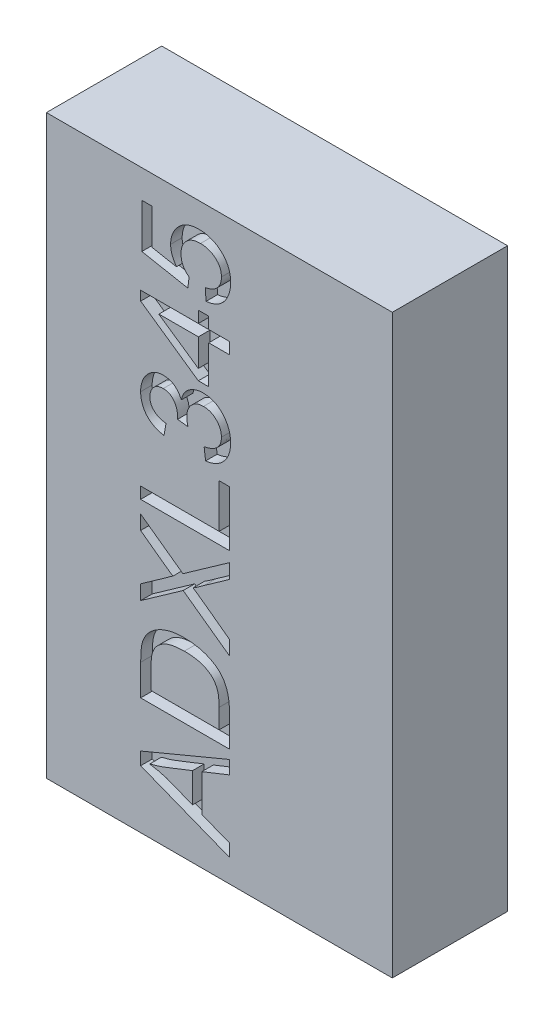
from build123d import *

# Parameters (mm, degrees)
ESQUISSE1_W             = 3
ESQUISSE1_H             = 5
BOSS_EXTRU_1_DEPTH      = 1
ENL_V_MAT_EXTRU_1_DEPTH = 0.1


with BuildPart() as part:
    # Esquisse1 → Boss.-Extru.1 (new body)
    with BuildSketch(Plane.XY):
        with Locations((1.5, 2.5)):
            Rectangle(ESQUISSE1_W, ESQUISSE1_H)
    extrude(amount=BOSS_EXTRU_1_DEPTH)

    # Esquisse2 → Enlèv. mat.-Extru.1 (cut)
    with BuildSketch(Plane(origin=(3.575593403, -1.280169581, 1), x_dir=(0, 1, 0), z_dir=(0, 0, 1))):
        Polygon((2.215385563, 1.987701117), (2.099373441, 1.987701117), (2.003843243, 2.227855591), (1.682699173, 2.227855591), (1.58826343, 1.987701117), (1.479912485, 1.987701117), (1.783232589, 2.758196722), (1.893616091, 2.758196722), align=None)
        with BuildLine():
            add(Edge.make_bspline(
                [(1.971791376, 2.307907082), (1.967832396, 2.31791427), (1.960138748, 2.337361649), (1.948903368, 2.365669848), (1.938184455, 2.392246268), (1.928424558, 2.417266631), (1.919145584, 2.440520895), (1.910707056, 2.462171677), (1.902915421, 2.482142575), (1.895704231, 2.500480169), (1.889117658, 2.517129673), (1.883393014, 2.532182819), (1.878135748, 2.545467514), (1.873830151, 2.557188955), (1.870066319, 2.567191171), (1.866926654, 2.575524808), (1.864399266, 2.582168124), (1.861000969, 2.592157003), (1.856410276, 2.606892042), (1.850228287, 2.627915403), (1.844114017, 2.651854672), (1.839876513, 2.668762643), (1.837642588, 2.677676179)],
                knots=[0, 0, 0, 0, 3.2286e-05, 6.2742e-05, 9.1369e-05, 0.000118254, 0.000143311, 0.00016648, 0.000187966, 0.000207622, 0.000225594, 0.00024168, 0.000255936, 0.000268453, 0.00027914, 0.000287997, 0.00029517, 0.00030046, 0.000319646, 0.000341467, 0.000366192, 0.000393761, 0.000393761, 0.000393761, 0.000393761], degree=3))
            Line((1.837642588, 2.677676179), (1.83545368, 2.677676179))
            add(Edge.make_bspline(
                [(1.83545368, 2.677676179), (1.83336846, 2.664888214), (1.829269492, 2.639750585), (1.821434644, 2.60292826), (1.813052097, 2.567447506), (1.806267044, 2.544489956), (1.802932761, 2.533208253)],
                knots=[0, 0, 0, 0, 3.8865e-05, 7.6397e-05, 0.000112916, 0.000148201, 0.000148201, 0.000148201, 0.000148201], degree=3))
            Line((1.802932761, 2.533208253), (1.714125638, 2.307907082))
            Line((1.714125638, 2.307907082), (1.971791376, 2.307907082))
        make_face(mode=Mode.SUBTRACT)
        with BuildLine():
            Line((2.292935445, 2.758196722), (2.560294919, 2.758196722))
            add(Edge.make_bspline(
                [(2.560294919, 2.758196722), (2.571604659, 2.758090271), (2.593449606, 2.75788466), (2.624961046, 2.756782222), (2.653990214, 2.754303956), (2.680934656, 2.751416211), (2.706472766, 2.746569958), (2.731132519, 2.739222476), (2.755156582, 2.729055549), (2.778577898, 2.716626526), (2.801041672, 2.701598305), (2.822077569, 2.683785157), (2.841655838, 2.663391224), (2.859579481, 2.640466245), (2.875983127, 2.615486677), (2.890545771, 2.588482764), (2.903168928, 2.559645731), (2.914106584, 2.528816993), (2.923012421, 2.495461871), (2.928873872, 2.458901444), (2.93271717, 2.419154718), (2.933132095, 2.391512441), (2.933347377, 2.377170385)],
                knots=[0, 0, 0, 0, 3.3931e-05, 6.5539e-05, 9.4559e-05, 0.000121322, 0.000146803, 0.000172426, 0.000198356, 0.000224936, 0.000251865, 0.000279271, 0.000307468, 0.000336527, 0.000366448, 0.00039702, 0.000428453, 0.000460793, 0.000495077, 0.000531859, 0.000571749, 0.000614763, 0.000614763, 0.000614763, 0.000614763], degree=3))
            add(Edge.make_bspline(
                [(2.933347377, 2.377170385), (2.933137397, 2.363296521), (2.932726033, 2.336116683), (2.928617201, 2.296331795), (2.922533571, 2.258356872), (2.913623297, 2.222258575), (2.902013577, 2.188147171), (2.888079842, 2.155810973), (2.871482366, 2.12545775), (2.855542885, 2.101696656), (2.841471362, 2.083869301), (2.829794824, 2.071552838), (2.817416579, 2.059838403), (2.803978577, 2.049146775), (2.789683323, 2.03915623), (2.774317221, 2.030356629), (2.758158785, 2.022167891), (2.741103805, 2.014805883), (2.723128513, 2.008411154), (2.704190827, 2.00299655), (2.68447037, 1.998054523), (2.663659234, 1.994393829), (2.642012343, 1.991446494), (2.619434065, 1.989221443), (2.595956409, 1.988003718), (2.579996406, 1.987803253), (2.571864861, 1.987701117)],
                knots=[0, 0, 0, 0, 4.1608e-05, 8.1513e-05, 0.000119863, 0.000156912, 0.000192906, 0.000227848, 0.000262413, 0.000296541, 0.00031356, 0.000330484, 0.000347408, 0.000364647, 0.000381952, 0.000399678, 0.000417718, 0.000436277, 0.000455366, 0.00047491, 0.000495349, 0.000516326, 0.00053826, 0.000560881, 0.000584367, 0.000608762, 0.000608762, 0.000608762, 0.000608762], degree=3))
            Line((2.571864861, 1.987701117), (2.292935445, 1.987701117))
            Line((2.292935445, 1.987701117), (2.292935445, 2.758196722))
        make_face()
        with BuildLine():
            Line((2.39299981, 2.077759044), (2.562014775, 2.077759044))
            add(Edge.make_bspline(
                [(2.562014775, 2.077759044), (2.570405931, 2.077877421), (2.586726192, 2.078107657), (2.61052324, 2.079071963), (2.632873027, 2.081260942), (2.654215799, 2.083636886), (2.675069147, 2.088186619), (2.695663361, 2.095690484), (2.716484693, 2.105629542), (2.733564726, 2.116012559), (2.747099247, 2.125858018), (2.756845022, 2.134591049), (2.766191149, 2.144429733), (2.775065522, 2.155362251), (2.783503833, 2.167445308), (2.791528049, 2.180640762), (2.798925558, 2.195006208), (2.806058225, 2.210391847), (2.812480537, 2.227032841), (2.818102897, 2.244990005), (2.822714965, 2.264285756), (2.826669657, 2.284777117), (2.829558194, 2.306606015), (2.831774859, 2.329705357), (2.832983352, 2.354121876), (2.833181512, 2.370810931), (2.833283013, 2.379359293)],
                knots=[0, 0, 0, 0, 2.5177e-05, 4.8967e-05, 7.1418e-05, 9.2537e-05, 0.000113362, 0.000135269, 0.000158138, 0.000182485, 0.000195119, 0.000208298, 0.000221679, 0.000235793, 0.000250498, 0.000265862, 0.000282086, 0.000298947, 0.000316717, 0.000335557, 0.000355352, 0.000376204, 0.000398139, 0.000421382, 0.000445805, 0.00047145, 0.00047145, 0.00047145, 0.00047145], degree=3))
            add(Edge.make_bspline(
                [(2.833283013, 2.379359293), (2.833178673, 2.388848293), (2.832972612, 2.40758823), (2.830869496, 2.435192249), (2.827572834, 2.461849172), (2.823208983, 2.487619074), (2.816768849, 2.512365828), (2.808466474, 2.536173749), (2.797300569, 2.558551379), (2.784496859, 2.579720942), (2.769978886, 2.598900318), (2.754298618, 2.615683159), (2.737483477, 2.629661416), (2.719522804, 2.640474161), (2.701384174, 2.649175759), (2.683428523, 2.656158419), (2.665594203, 2.661017926), (2.647582077, 2.664211526), (2.628491085, 2.665962795), (2.607422229, 2.667176578), (2.583909275, 2.667945294), (2.567383388, 2.668072301), (2.558731413, 2.668138794)],
                knots=[0, 0, 0, 0, 2.8463e-05, 5.6211e-05, 8.2993e-05, 0.000109032, 0.000134554, 0.000159627, 0.00018452, 0.000209431, 0.000233759, 0.000256544, 0.000278204, 0.00029912, 0.00031926, 0.000338511, 0.000356832, 0.00037462, 0.00039332, 0.000414308, 0.00043793, 0.000463886, 0.000463886, 0.000463886, 0.000463886], degree=3))
            Line((2.558731413, 2.668138794), (2.39299981, 2.668138794))
            Line((2.39299981, 2.668138794), (2.39299981, 2.077759044))
        make_face(mode=Mode.SUBTRACT)
        with BuildLine():
            Line((3.693836546, 1.987701117), (3.567505286, 1.987701117))
            Line((3.567505286, 1.987701117), (3.413656326, 2.20549746))
            add(Edge.make_bspline(
                [(3.413656326, 2.20549746), (3.409424593, 2.211274952), (3.40133008, 2.222326215), (3.389902693, 2.23826559), (3.379816461, 2.25275667), (3.370850267, 2.265678925), (3.362954299, 2.276973317), (3.356635761, 2.287057199), (3.351247176, 2.295424188), (3.348234461, 2.300601421), (3.346894633, 2.302903864)],
                knots=[0, 0, 0, 0, 2.1484e-05, 4.1096e-05, 5.8836e-05, 7.445e-05, 8.8284e-05, 0.000100168, 0.000110145, 0.000118135, 0.000118135, 0.000118135, 0.000118135], degree=3))
            Line((3.346894633, 2.302903864), (3.344862076, 2.302903864))
            add(Edge.make_bspline(
                [(3.344862076, 2.302903864), (3.344568653, 2.302112715), (3.343664692, 2.299675384), (3.34066468, 2.295195058), (3.336484823, 2.288121594), (3.330052366, 2.278983783), (3.322137106, 2.267342704), (3.312286891, 2.253512654), (3.300622221, 2.237373259), (3.287449966, 2.21874919), (3.272160434, 2.197939346), (3.255204872, 2.174760416), (3.236569338, 2.149168611), (3.216079645, 2.121343557), (3.193748411, 2.091277213), (3.1697549, 2.058784504), (3.144045422, 2.023956808), (3.126141951, 2.000042162), (3.116902946, 1.987701117)],
                knots=[0, 0, 0, 0, 2.526e-06, 7.782e-06, 1.6068e-05, 2.7213e-05, 4.1265e-05, 5.8313e-05, 7.8143e-05, 0.000101007, 0.000126745, 0.000155609, 0.000187164, 0.000221718, 0.000259274, 0.00029952, 0.000342893, 0.000389141, 0.000389141, 0.000389141, 0.000389141], degree=3))
            Line((3.116902946, 1.987701117), (2.993385996, 1.987701117))
            Line((2.993385996, 1.987701117), (3.283729003, 2.389365729))
            Line((3.283729003, 2.389365729), (3.023405305, 2.758196722))
            Line((3.023405305, 2.758196722), (3.149580215, 2.758196722))
            Line((3.149580215, 2.758196722), (3.309839548, 2.531175695))
            add(Edge.make_bspline(
                [(3.309839548, 2.531175695), (3.313898808, 2.526155768), (3.321616135, 2.516612052), (3.331832326, 2.502556197), (3.34059529, 2.489927671), (3.34542748, 2.48169271), (3.347676386, 2.477860151)],
                knots=[0, 0, 0, 0, 1.9363e-05, 3.6813e-05, 5.2121e-05, 6.5448e-05, 6.5448e-05, 6.5448e-05, 6.5448e-05], degree=3))
            add(Edge.make_bspline(
                [(3.347676386, 2.477860151), (3.348651861, 2.479537046), (3.350972319, 2.483526039), (3.355427719, 2.490169994), (3.360986738, 2.498606823), (3.367950695, 2.508608646), (3.375999439, 2.520376862), (3.385686045, 2.533628475), (3.396289906, 2.548770057), (3.408510787, 2.565368753), (3.421678206, 2.583802213), (3.436239834, 2.603800243), (3.452119378, 2.625454425), (3.469173582, 2.648818792), (3.487784162, 2.673715837), (3.507370045, 2.700431983), (3.52837534, 2.728782142), (3.54284884, 2.748194138), (3.550306724, 2.758196722)],
                knots=[0, 0, 0, 0, 5.819e-06, 1.3841e-05, 2.3989e-05, 3.6132e-05, 5.0401e-05, 6.6759e-05, 8.537e-05, 0.000105855, 0.000128592, 0.00015333, 0.000180067, 0.00020915, 0.000240108, 0.000273318, 0.000308529, 0.00034596, 0.00034596, 0.00034596, 0.00034596], degree=3))
            Line((3.550306724, 2.758196722), (3.673823673, 2.758196722))
            Line((3.673823673, 2.758196722), (3.408809458, 2.391554637))
            Line((3.408809458, 2.391554637), (3.693836546, 1.987701117))
        make_face()
        Polygon((4.264203423, 1.987701117), (3.783894474, 1.987701117), (3.783894474, 2.758196722), (3.883958838, 2.758196722), (3.883958838, 2.077759044), (4.264203423, 2.077759044), align=None)
        with BuildLine():
            add(Edge.make_bspline(
                [(4.708551741, 2.404062683), (4.714413371, 2.402807106), (4.725901575, 2.400346301), (4.74242851, 2.395026365), (4.757740669, 2.388216021), (4.772125473, 2.380493597), (4.785210765, 2.371093415), (4.797213225, 2.360516515), (4.808144698, 2.348606456), (4.817893614, 2.335586929), (4.826336046, 2.321696309), (4.833969354, 2.307549449), (4.84035225, 2.293069643), (4.845551792, 2.278217589), (4.84963253, 2.263122636), (4.85242592, 2.247637233), (4.854190221, 2.231909358), (4.854451983, 2.221293444), (4.854583173, 2.215972948)],
                knots=[0, 0, 0, 0, 1.7977e-05, 3.5233e-05, 5.1965e-05, 6.82e-05, 8.4121e-05, 0.000100183, 0.000116117, 0.000132534, 0.000148891, 0.000164839, 0.00018073, 0.000196306, 0.000212008, 0.000227586, 0.000243471, 0.000259431, 0.000259431, 0.000259431, 0.000259431], degree=3))
            add(Edge.make_bspline(
                [(4.854583173, 2.215972948), (4.854322108, 2.207467322), (4.85380902, 2.190750677), (4.850384804, 2.16625119), (4.844424536, 2.142975441), (4.83601866, 2.120882355), (4.825435809, 2.099810555), (4.812150236, 2.080099666), (4.796707948, 2.061440326), (4.778989878, 2.044326186), (4.759702421, 2.028772941), (4.739300655, 2.015109498), (4.717989196, 2.003442689), (4.69564124, 1.99407496), (4.672429898, 1.98663842), (4.648219796, 1.98156114), (4.623115226, 1.978329245), (4.606047921, 1.977908303), (4.597386486, 1.97769468)],
                knots=[0, 0, 0, 0, 2.5516e-05, 5.0148e-05, 7.4038e-05, 9.7443e-05, 0.000120938, 0.000144614, 0.000168597, 0.000193474, 0.000218381, 0.000242838, 0.000267045, 0.000291148, 0.000315426, 0.000340051, 0.000365262, 0.000391239, 0.000391239, 0.000391239, 0.000391239], degree=3))
            add(Edge.make_bspline(
                [(4.597386486, 1.97769468), (4.589142349, 1.977861368), (4.572969254, 1.97818837), (4.549301769, 1.981154386), (4.526682285, 1.98549626), (4.505299514, 1.992258233), (4.484831144, 2.000432102), (4.465611971, 2.010829625), (4.447464989, 2.022994494), (4.430480977, 2.036794018), (4.415040979, 2.052347993), (4.401068102, 2.069018824), (4.388931531, 2.087079275), (4.378478517, 2.106221389), (4.369814996, 2.126669245), (4.362823916, 2.148220592), (4.357407327, 2.17101582), (4.355323247, 2.186711756), (4.354261351, 2.19470927)],
                knots=[0, 0, 0, 0, 2.4721e-05, 4.8497e-05, 7.1464e-05, 9.3718e-05, 0.000115668, 0.000137493, 0.000159132, 0.000181133, 0.000203023, 0.000224784, 0.000246293, 0.000268192, 0.000290118, 0.000312812, 0.000336098, 0.000360288, 0.000360288, 0.000360288, 0.000360288], degree=3))
            Line((4.354261351, 2.19470927), (4.454325715, 2.207842718))
            add(Edge.make_bspline(
                [(4.454325715, 2.207842718), (4.455498977, 2.201727599), (4.45778023, 2.189837551), (4.462387124, 2.172795697), (4.467499824, 2.156888277), (4.473450868, 2.1421507), (4.480097044, 2.128586686), (4.487533713, 2.116283458), (4.495511741, 2.105087389), (4.504247296, 2.095014189), (4.513878886, 2.086265633), (4.524054603, 2.078489254), (4.535083751, 2.07203959), (4.546876035, 2.066920069), (4.559328437, 2.062818401), (4.57251237, 2.059829306), (4.586449868, 2.058134774), (4.59597487, 2.057877307), (4.600826199, 2.057746172)],
                knots=[0, 0, 0, 0, 1.8674e-05, 3.6309e-05, 5.2922e-05, 6.8774e-05, 8.3948e-05, 9.8186e-05, 0.000111854, 0.00012515, 0.000138097, 0.000150824, 0.000163508, 0.000176319, 0.000189322, 0.000202787, 0.000216809, 0.000231363, 0.000231363, 0.000231363, 0.000231363], degree=3))
            add(Edge.make_bspline(
                [(4.600826199, 2.057746172), (4.606094795, 2.057921998), (4.616462326, 2.05826799), (4.631738685, 2.060239182), (4.646297011, 2.063954477), (4.660374968, 2.068696348), (4.673659296, 2.075299212), (4.686606766, 2.08283107), (4.698597923, 2.092226439), (4.710004873, 2.102625155), (4.720376473, 2.114086301), (4.729522327, 2.126318975), (4.737184358, 2.139250588), (4.74369554, 2.152685585), (4.748562895, 2.166925768), (4.751887554, 2.181772208), (4.754265334, 2.197187315), (4.754433458, 2.20767701), (4.754518808, 2.213002287)],
                knots=[0, 0, 0, 0, 1.5811e-05, 3.1112e-05, 4.6091e-05, 6.0826e-05, 7.5581e-05, 9.0517e-05, 0.000105683, 0.000121176, 0.000136783, 0.000151981, 0.000166916, 0.000181812, 0.000196695, 0.000211941, 0.000227419, 0.000243379, 0.000243379, 0.000243379, 0.000243379], degree=3))
            add(Edge.make_bspline(
                [(4.754518808, 2.213002287), (4.754421958, 2.218118089), (4.754232382, 2.228131805), (4.752050995, 2.242823717), (4.748886394, 2.256899275), (4.744143935, 2.270248175), (4.738094544, 2.282878556), (4.730969625, 2.294975677), (4.722243819, 2.306301226), (4.712288502, 2.316818096), (4.701398277, 2.326502699), (4.689633112, 2.335071732), (4.67690029, 2.342021623), (4.663481873, 2.347924711), (4.649211245, 2.352404613), (4.634153653, 2.35572508), (4.618280369, 2.357587635), (4.607449733, 2.357820425), (4.601920653, 2.357939265)],
                knots=[0, 0, 0, 0, 1.5335e-05, 3.0017e-05, 4.4467e-05, 5.856e-05, 7.2407e-05, 8.6431e-05, 0.000100597, 0.000115197, 0.000129817, 0.000144267, 0.000158754, 0.000173249, 0.000188182, 0.000203546, 0.000219449, 0.000236034, 0.000236034, 0.000236034, 0.000236034], degree=3))
            add(Edge.make_bspline(
                [(4.601920653, 2.357939265), (4.597068619, 2.357805548), (4.586811476, 2.357522873), (4.570682413, 2.35548875), (4.552988375, 2.352375536), (4.540773447, 2.349459687), (4.534377207, 2.347932828)],
                knots=[0, 0, 0, 0, 1.4554e-05, 3.0767e-05, 4.8709e-05, 6.8432e-05, 6.8432e-05, 6.8432e-05, 6.8432e-05], degree=3))
            Line((4.534377207, 2.347932828), (4.545165396, 2.437990756))
            add(Edge.make_bspline(
                [(4.545165396, 2.437990756), (4.551056577, 2.437976534), (4.5621675, 2.437949711), (4.577846904, 2.438912682), (4.591587779, 2.439647627), (4.603888096, 2.441232205), (4.615483424, 2.443855199), (4.627384509, 2.447471896), (4.639817099, 2.452575519), (4.652804765, 2.458627656), (4.665528747, 2.46618218), (4.677396766, 2.475263838), (4.687862152, 2.486068039), (4.69737458, 2.498051597), (4.705140848, 2.511753072), (4.710559609, 2.527097397), (4.713944021, 2.543953446), (4.71430516, 2.555705653), (4.714493063, 2.561820407)],
                knots=[0, 0, 0, 0, 1.7668e-05, 3.3323e-05, 4.7114e-05, 5.8944e-05, 7.0476e-05, 8.2741e-05, 9.6212e-05, 0.000110759, 0.000125694, 0.000140518, 0.000155444, 0.000170706, 0.000186318, 0.000202441, 0.000219336, 0.000237662, 0.000237662, 0.000237662, 0.000237662], degree=3))
            add(Edge.make_bspline(
                [(4.714493063, 2.561820407), (4.714348893, 2.566305614), (4.714068054, 2.575042736), (4.712583575, 2.587796098), (4.70970954, 2.599721102), (4.705874033, 2.610957143), (4.700553564, 2.621274607), (4.694577252, 2.631097918), (4.687084831, 2.639879666), (4.675906444, 2.650350428), (4.660428829, 2.661453977), (4.64002553, 2.671041414), (4.618169352, 2.677184722), (4.603056214, 2.677820971), (4.595353929, 2.678145231)],
                knots=[0, 0, 0, 0, 1.3461e-05, 2.6221e-05, 3.8433e-05, 5.0202e-05, 6.1739e-05, 7.3191e-05, 8.4621e-05, 9.6235e-05, 0.000119099, 0.00014141, 0.000163597, 0.000186657, 0.000186657, 0.000186657, 0.000186657], degree=3))
            add(Edge.make_bspline(
                [(4.595353929, 2.678145231), (4.590970945, 2.67801513), (4.582327546, 2.677758567), (4.569702181, 2.676036296), (4.557675732, 2.673168836), (4.546228722, 2.669366436), (4.535512709, 2.664044584), (4.525331093, 2.657868905), (4.515830137, 2.650364621), (4.507000212, 2.641811683), (4.498815065, 2.632277369), (4.491600434, 2.621622014), (4.485034799, 2.610080942), (4.479273558, 2.597514554), (4.474214669, 2.58405736), (4.470273001, 2.569573469), (4.466718912, 2.554208263), (4.465142799, 2.543541425), (4.464332152, 2.53805512)],
                knots=[0, 0, 0, 0, 1.3148e-05, 2.5929e-05, 3.814e-05, 5.0205e-05, 6.2022e-05, 7.3955e-05, 8.5872e-05, 9.8256e-05, 0.000110789, 0.000123495, 0.000136799, 0.00015058, 0.000164927, 0.000179874, 0.000195578, 0.000212209, 0.000212209, 0.000212209, 0.000212209], degree=3))
            Line((4.464332152, 2.53805512), (4.364267787, 2.555566384))
            add(Edge.make_bspline(
                [(4.364267787, 2.555566384), (4.365847642, 2.563782593), (4.368945208, 2.579891824), (4.375842107, 2.602898385), (4.383449043, 2.624534899), (4.393046326, 2.644281737), (4.403501649, 2.662747736), (4.415874314, 2.679257716), (4.429162526, 2.694540052), (4.444098823, 2.70789174), (4.459968624, 2.719755698), (4.476724472, 2.729940841), (4.494089913, 2.7388707), (4.512425693, 2.745705685), (4.531319711, 2.751559806), (4.551090017, 2.755333405), (4.571579463, 2.757765682), (4.585496654, 2.758051885), (4.592539619, 2.758196722)],
                knots=[0, 0, 0, 0, 2.5083e-05, 4.918e-05, 7.1982e-05, 9.3802e-05, 0.00011496, 0.000135537, 0.000155584, 0.00017562, 0.000195508, 0.000214949, 0.000234387, 0.000253987, 0.000273575, 0.000293659, 0.000314275, 0.000335397, 0.000335397, 0.000335397, 0.000335397], degree=3))
            add(Edge.make_bspline(
                [(4.592539619, 2.758196722), (4.600312122, 2.758009436), (4.615538829, 2.757642533), (4.637893011, 2.754969663), (4.659218963, 2.750391799), (4.679638157, 2.744220459), (4.698957653, 2.735969165), (4.717393952, 2.726124195), (4.734755248, 2.714287426), (4.751127244, 2.700990675), (4.765782924, 2.686178278), (4.778971786, 2.670692783), (4.789949523, 2.654194854), (4.798893786, 2.63686668), (4.806049826, 2.618771177), (4.81097771, 2.599816763), (4.814086414, 2.580060152), (4.814398523, 2.566627017), (4.814557427, 2.55978785)],
                knots=[0, 0, 0, 0, 2.3315e-05, 4.5675e-05, 6.7417e-05, 8.8683e-05, 0.000109562, 0.000130339, 0.000151284, 0.000172504, 0.00019351, 0.000213709, 0.000233439, 0.00025281, 0.000272118, 0.000291687, 0.000311455, 0.000331958, 0.000331958, 0.000331958, 0.000331958], degree=3))
            add(Edge.make_bspline(
                [(4.814557427, 2.55978785), (4.814216584, 2.551167222), (4.813553979, 2.534408557), (4.808720319, 2.510200849), (4.800271259, 2.487972001), (4.788622968, 2.467504313), (4.773350744, 2.449120907), (4.754953405, 2.432510161), (4.733180826, 2.417870117), (4.716950185, 2.410110437), (4.708551741, 2.40609524)],
                knots=[0, 0, 0, 0, 2.5855e-05, 5.0263e-05, 7.3668e-05, 9.692e-05, 0.000120583, 0.000145046, 0.000171065, 0.000198964, 0.000198964, 0.000198964, 0.000198964], degree=3))
            Line((4.708551741, 2.40609524), (4.708551741, 2.404062683))
        make_face()
        Polygon((5.454969359, 2.167816972), (5.354904994, 2.167816972), (5.354904994, 1.987701117), (5.25484063, 1.987701117), (5.25484063, 2.167816972), (4.924628228, 2.167816972), (4.924628228, 2.2578749), (5.272664595, 2.758196722), (5.354904994, 2.758196722), (5.354904994, 2.2578749), (5.454969359, 2.2578749), align=None)
        Polygon((5.25484063, 2.2578749), (5.25484063, 2.599657245), (5.252808073, 2.599657245), (5.017187765, 2.2578749), align=None, mode=Mode.SUBTRACT)
        with BuildLine():
            add(Edge.make_bspline(
                [(5.68589915, 2.447684491), (5.691695105, 2.451654432), (5.703080947, 2.459453165), (5.72061318, 2.469932991), (5.738507239, 2.478396633), (5.756369313, 2.48580496), (5.774525233, 2.49118648), (5.792809091, 2.495160941), (5.811227766, 2.49756839), (5.823585031, 2.497876078), (5.829741673, 2.498029375)],
                knots=[0, 0, 0, 0, 2.1075e-05, 4.14e-05, 6.119e-05, 8.0411e-05, 9.9355e-05, 0.000117908, 0.000136506, 0.000154972, 0.000154972, 0.000154972, 0.000154972], degree=3))
            add(Edge.make_bspline(
                [(5.829741673, 2.498029375), (5.837517302, 2.497811285), (5.852871406, 2.497380636), (5.875557583, 2.494183442), (5.897441491, 2.488876092), (5.918614342, 2.481466493), (5.938931337, 2.471916419), (5.958499674, 2.460213545), (5.977256733, 2.446403574), (5.995116163, 2.430688255), (6.011763473, 2.413397496), (6.025908126, 2.394111738), (6.038366689, 2.373734731), (6.048055022, 2.351673078), (6.056073851, 2.328398903), (6.061376315, 2.303617819), (6.064787071, 2.277462114), (6.065167093, 2.259553977), (6.065361981, 2.250370073)],
                knots=[0, 0, 0, 0, 2.3322e-05, 4.6053e-05, 6.8578e-05, 9.078e-05, 0.000113232, 0.00013581, 0.000159076, 0.000183006, 0.000207117, 0.000230913, 0.000254617, 0.00027862, 0.000303045, 0.000328347, 0.000354508, 0.000382047, 0.000382047, 0.000382047, 0.000382047], degree=3))
            add(Edge.make_bspline(
                [(6.065361981, 2.250370073), (6.065173468, 2.241081342), (6.064801454, 2.222750848), (6.061201408, 2.195820613), (6.055714573, 2.169916519), (6.047542869, 2.145169651), (6.03750933, 2.121354854), (6.024847677, 2.098749761), (6.010042608, 2.077185973), (5.993169652, 2.056846481), (5.974375044, 2.038340675), (5.954025905, 2.022048665), (5.932298817, 2.008236226), (5.909015325, 1.997081248), (5.88442113, 1.988221695), (5.858314787, 1.982292374), (5.830904033, 1.978347006), (5.812140668, 1.97791553), (5.802536674, 1.97769468)],
                knots=[0, 0, 0, 0, 2.7852e-05, 5.4963e-05, 8.1368e-05, 0.000107178, 0.000133025, 0.00015878, 0.000184758, 0.000211403, 0.000237937, 0.000263747, 0.000289469, 0.000314993, 0.000341054, 0.000367715, 0.000395178, 0.000423974, 0.000423974, 0.000423974, 0.000423974], degree=3))
            add(Edge.make_bspline(
                [(5.802536674, 1.97769468), (5.794660098, 1.977828607), (5.77912636, 1.978092731), (5.756227982, 1.980674011), (5.734099458, 1.984851897), (5.712795304, 1.990862917), (5.692237515, 1.998296113), (5.672556268, 2.007649941), (5.653673501, 2.018570722), (5.635654243, 2.031067109), (5.618860145, 2.045131321), (5.604152387, 2.061308366), (5.591034295, 2.078806616), (5.580117872, 2.098114671), (5.570800109, 2.118862371), (5.563479903, 2.141289838), (5.558161292, 2.165397033), (5.556095203, 2.182075418), (5.555033723, 2.190644155)],
                knots=[0, 0, 0, 0, 2.3622e-05, 4.6586e-05, 6.9032e-05, 9.111e-05, 0.000112923, 0.000134535, 0.000156391, 0.000178294, 0.000200256, 0.000221943, 0.000243738, 0.00026573, 0.000288336, 0.000311871, 0.000336376, 0.000362268, 0.000362268, 0.000362268, 0.000362268], degree=3))
            Line((5.555033723, 2.190644155), (5.655098087, 2.197836282))
            add(Edge.make_bspline(
                [(5.655098087, 2.197836282), (5.656176322, 2.192140833), (5.658277666, 2.181041115), (5.662494168, 2.165035801), (5.667627941, 2.150119788), (5.673759382, 2.136345457), (5.680581663, 2.123640201), (5.68835023, 2.112083827), (5.696883548, 2.101611333), (5.706355729, 2.092321398), (5.716540269, 2.084179665), (5.727349742, 2.077155986), (5.738680758, 2.071123343), (5.750661294, 2.066330189), (5.763117511, 2.062324311), (5.776245782, 2.059791462), (5.789869976, 2.057910212), (5.799194175, 2.057801532), (5.803943829, 2.057746172)],
                knots=[0, 0, 0, 0, 1.7386e-05, 3.3883e-05, 4.9607e-05, 6.4656e-05, 7.9069e-05, 9.2815e-05, 0.000106368, 0.000119525, 0.000132539, 0.000145419, 0.000158148, 0.000170981, 0.000184086, 0.000197332, 0.000211043, 0.000225279, 0.000225279, 0.000225279, 0.000225279], degree=3))
            add(Edge.make_bspline(
                [(5.803943829, 2.057746172), (5.809791339, 2.057874459), (5.821281799, 2.058126545), (5.838084087, 2.060763842), (5.854118216, 2.064722234), (5.869195992, 2.070590735), (5.883448434, 2.077977194), (5.896747376, 2.087156016), (5.909378399, 2.097790723), (5.920775511, 2.110169999), (5.931297242, 2.123538092), (5.940319575, 2.137944786), (5.948021997, 2.153080697), (5.954482917, 2.168835721), (5.959362536, 2.185452233), (5.962677841, 2.202790887), (5.965046838, 2.22085938), (5.965213034, 2.233163493), (5.965297617, 2.239425533)],
                knots=[0, 0, 0, 0, 1.7529e-05, 3.4444e-05, 5.0902e-05, 6.6988e-05, 8.2863e-05, 9.8952e-05, 0.000115368, 0.000132292, 0.000149337, 0.000166341, 0.000183193, 0.000200236, 0.000217353, 0.000235046, 0.000253159, 0.000271931, 0.000271931, 0.000271931, 0.000271931], degree=3))
            add(Edge.make_bspline(
                [(5.965297617, 2.239425533), (5.965123887, 2.245787748), (5.964785489, 2.258180269), (5.962842418, 2.276260404), (5.95913458, 2.293224301), (5.954381323, 2.309310601), (5.947978164, 2.324313633), (5.940052236, 2.338224572), (5.930778578, 2.351121929), (5.92017231, 2.362944809), (5.908518965, 2.373575048), (5.895854209, 2.382673711), (5.882544324, 2.390542184), (5.868382518, 2.397066694), (5.853264014, 2.401784299), (5.837450678, 2.405491743), (5.820774131, 2.407452786), (5.809420463, 2.407796291), (5.803631128, 2.407971447)],
                knots=[0, 0, 0, 0, 1.9091e-05, 3.7186e-05, 5.445e-05, 7.1118e-05, 8.7439e-05, 0.000103264, 0.000119059, 0.000135003, 0.000150832, 0.000166281, 0.0001817, 0.000197163, 0.000212936, 0.000229131, 0.000245829, 0.000263201, 0.000263201, 0.000263201, 0.000263201], degree=3))
            add(Edge.make_bspline(
                [(5.803631128, 2.407971447), (5.796321434, 2.407775064), (5.782093272, 2.407392809), (5.761419008, 2.404019587), (5.742030972, 2.398573131), (5.72390308, 2.390849838), (5.707038655, 2.380972438), (5.691618449, 2.368738795), (5.677362584, 2.354497563), (5.669342214, 2.343515071), (5.665260874, 2.337926392)],
                knots=[0, 0, 0, 0, 2.1916e-05, 4.266e-05, 6.2654e-05, 8.2199e-05, 0.000101613, 0.000121099, 0.00014111, 0.000161844, 0.000161844, 0.000161844, 0.000161844], degree=3))
            Line((5.665260874, 2.337926392), (5.575046596, 2.34855823))
            Line((5.575046596, 2.34855823), (5.650563921, 2.748190286))
            Line((5.650563921, 2.748190286), (6.035342672, 2.748190286))
            Line((6.035342672, 2.748190286), (6.035342672, 2.658132358))
            Line((6.035342672, 2.658132358), (5.725768545, 2.658132358))
            Line((5.725768545, 2.658132358), (5.68589915, 2.447684491))
        make_face()
    extrude(amount=-ENL_V_MAT_EXTRU_1_DEPTH, mode=Mode.SUBTRACT)


solid = part.part
